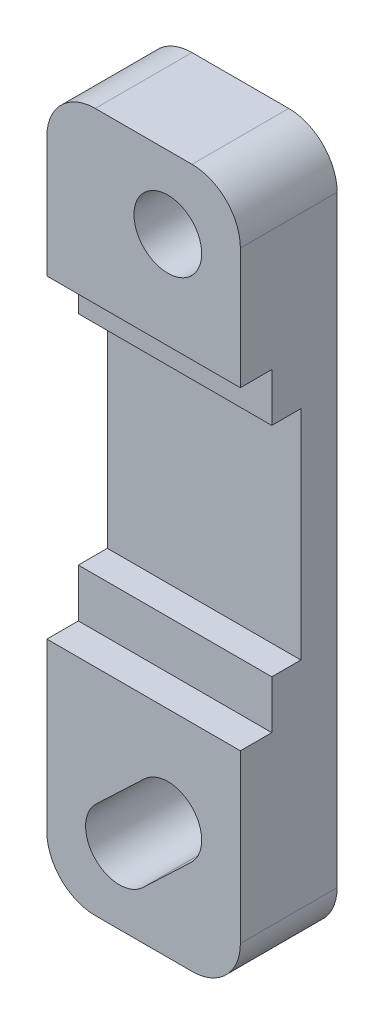
from build123d import *

# Parameters (mm, degrees)
SKETCH1_R           = 1.4
BOSS_EXTRUDE1_DEPTH = 4
CUT_EXTRUDE1_DEPTH  = 9


with BuildPart() as part:
    # Sketch1 → Boss-Extrude1 (new body)
    with BuildSketch(Plane.XY):
        with BuildLine():
            Line((-5, 11.5), (-5, -13.4))
            ThreePointArc((-5, -13.4), (-4.414213562, -14.814213562), (-3, -15.4))
            Line((-3, -15.4), (1, -15.4))
            ThreePointArc((1, -15.4), (2.414213562, -14.814213562), (3, -13.4))
            Line((3, -13.4), (3, 11.5))
            ThreePointArc((3, 11.5), (2.414213562, 12.914213562), (1, 13.5))
            Line((1, 13.5), (-3, 13.5))
            ThreePointArc((-3, 13.5), (-4.414213562, 12.914213562), (-5, 11.5))
        make_face()
        with Locations((0, 10.5)):
            Circle(SKETCH1_R, mode=Mode.SUBTRACT)
        with BuildLine():
            Line((0.964249247, -11.514999207), (-1.035750753, -13.414999207))
            ThreePointArc((-1.035750753, -13.414999207), (-3.014999207, -13.364249247), (-2.964249247, -11.385000793))
            Line((-2.964249247, -11.385000793), (-0.964249247, -9.485000793))
            ThreePointArc((-0.964249247, -9.485000793), (1.014999207, -9.535750753), (0.964249247, -11.514999207))
        make_face(mode=Mode.SUBTRACT)
    extrude(amount=BOSS_EXTRUDE1_DEPTH)

    # Sketch2 → Cut-Extrude1 (cut, through all)
    with BuildSketch(Plane(origin=(3, 0, 0), x_dir=(0, 0, -1), z_dir=(1, 0, 0))):
        Polygon((-4, 6.5), (-2.7, 6.5), (-2.7, 4.5), (-1.5, 4.5), (-1.5, -4.5), (-2.7, -4.5), (-2.7, -6.5), (-4, -6.5), align=None)
    extrude(amount=-CUT_EXTRUDE1_DEPTH, mode=Mode.SUBTRACT)


solid = part.part
